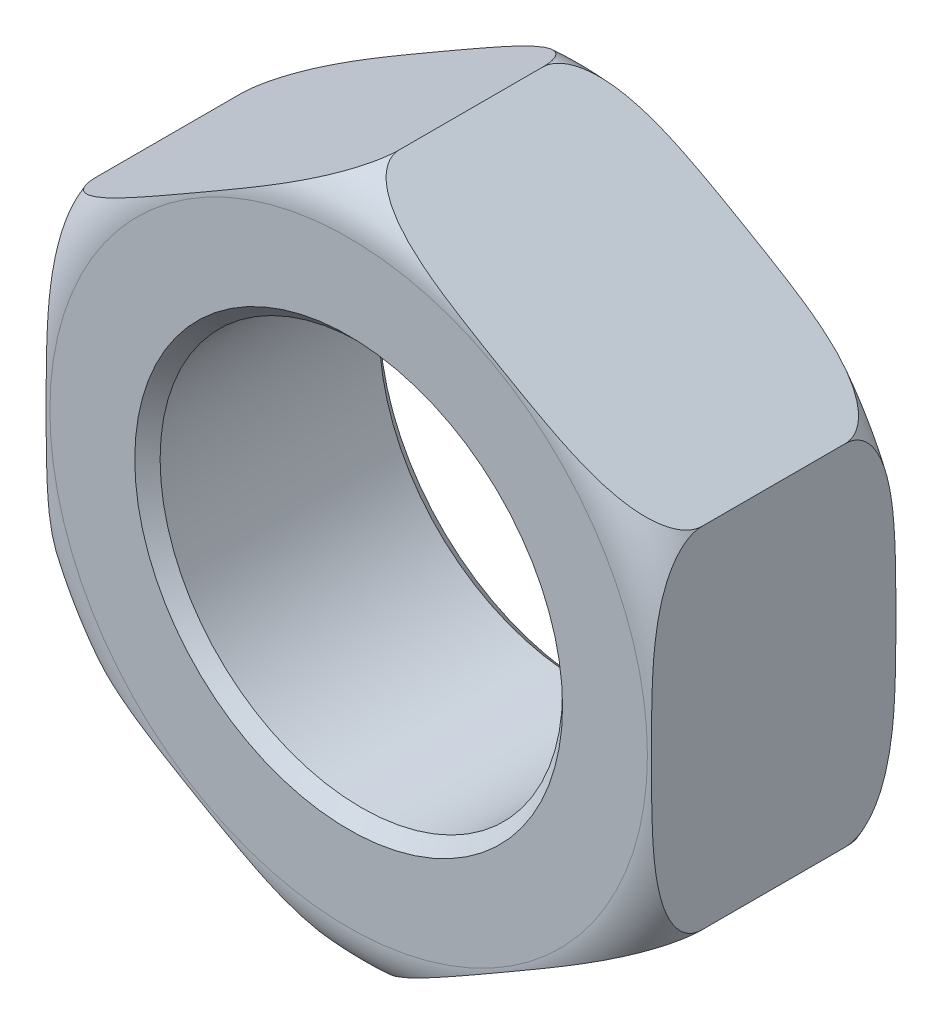
from build123d import *

# Parameters (mm, degrees)
SKETCH1_R      = 7.9375
EXTRUDE1_DEPTH = 4.826


with BuildPart() as part:
    # Sketch1 → Extrude1 (new body, symmetric)
    with BuildSketch(Plane.XY):
        Polygon((0, 13.784815027), (-11.938, 6.892407514), (-11.938, -6.892407514), (0, -13.784815027), (11.938, -6.892407514), (11.938, 6.892407514), align=None)
        Circle(SKETCH1_R, mode=Mode.SUBTRACT)
    extrude(amount=EXTRUDE1_DEPTH, both=True)

    # Sketch2 → Detail (revolve, cut)
    with BuildSketch(Plane(origin=(0, 0, 0), x_dir=(0, 0, -1), z_dir=(1, 0, 0))):
        Polygon((4.826, 7.9375), (4.826, 8.4375), (4.326, 7.9375), align=None)
        with BuildLine():
            Line((4.826, 13.784815027), (4.826, 11.784815027))
            ThreePointArc((4.826, 11.784815027), (4.240213562, 13.19902859), (2.826, 13.784815027))
            Line((2.826, 13.784815027), (4.826, 13.784815027))
        make_face()
        with BuildLine():
            Line((-2.826, 13.784815027), (-4.826, 13.784815027))
            Line((-4.826, 13.784815027), (-4.826, 11.784815027))
            ThreePointArc((-4.826, 11.784815027), (-4.240213562, 13.19902859), (-2.826, 13.784815027))
        make_face()
        Polygon((-4.326, 7.9375), (-4.826, 7.9375), (-4.826, 8.4375), align=None)
    revolve(axis=Axis((0, 0, 0), (0, 0, -1)), mode=Mode.SUBTRACT)


solid = part.part
